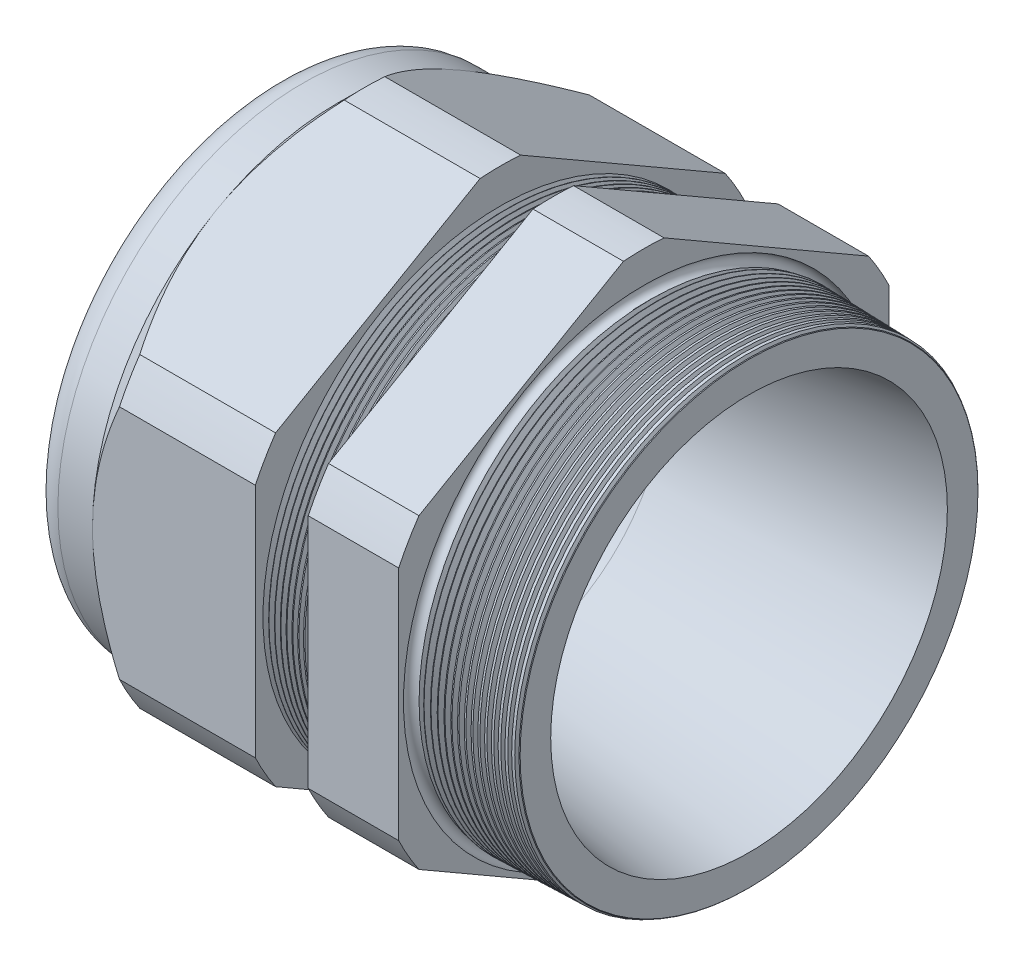
from build123d import *

# Parameters (mm, degrees)
SKETCH12_OUTSIDE_W = 170.928
SKETCH12_OUTSIDE_H = 170.928
CUT_EXTRUDE2_DEPTH = 55.5920168
FILLET4_R          = 3.81
SKETCH19_OUTSIDE_W = 98.176
SKETCH19_OUTSIDE_H = 105.328
SKETCH19_OUTSIDE_R = 32.512
CUT_EXTRUDE3_DEPTH = 3.99796
CUT_EXTRUDE3_DRAFT = -45
CHAMFER1_SIZE      = 0.260919487
CHAMFER1_SIZE2     = 0.254
SKETCH21_R         = 21.971
PLUG_DEPTH         = 12.7
SKETCH22_R         = 21.717
CUT_EXTRUDE4_DEPTH = 0.508
LPATTERN1_COUNT    = 9
LPATTERN1_PITCH    = 0.762
LPATTERN2_COUNT    = 16
LPATTERN2_PITCH    = 0.889
SKETCH32_R         = 0.889


with BuildPart() as part:
    # Sketch10 → Revolve2 (revolve)
    with BuildSketch(Plane.XY, mode=Mode.PRIVATE) as revolve2_sk:
        Polygon((-56.896, 21.971), (-26.89359112, 21.971), (6.096, 26.314137154), (6.096, 30.632137154), (-7.874, 30.997954479), (-7.874, 65.024), (-19.873976, 65.024), (-19.873976, 31.312184909), (-26.89359112, 31.496), (-26.89359112, 65.024), (-48.4960168, 65.024), (-48.4960168, 32.512), (-56.896, 32.512), align=None)
    revolve(revolve2_sk.sketch.rotate(Axis((0, 0, 0), (-1, 0, 0)), 90), axis=Axis((0, 0, 0), (-1, 0, 0)))  # turned: the seam where the file's is

    # Sketch12 outside → Cut-Extrude2 (cut, through all)
    with BuildSketch(Plane.ZY.offset(48.4960168)):
        Rectangle(SKETCH12_OUTSIDE_W, SKETCH12_OUTSIDE_H)
        with BuildLine():
            Line((-2.69124706, 35.987831689), (-29.82075294, 20.324604167))
            ThreePointArc((-29.82075294, 20.324604167), (-31.2534019, 18.04416), (-32.512, 15.663227523))
            Line((-32.512, 15.663227523), (-32.512, -15.663227523))
            ThreePointArc((-32.512, -15.663227523), (-31.2534019, -18.04416), (-29.82075294, -20.324604167))
            Line((-29.82075294, -20.324604167), (-2.69124706, -35.987831689))
            ThreePointArc((-2.69124706, -35.987831689), (0, -36.08832), (2.69124706, -35.987831689))
            Line((2.69124706, -35.987831689), (29.82075294, -20.324604167))
            ThreePointArc((29.82075294, -20.324604167), (31.2534019, -18.04416), (32.512, -15.663227523))
            Line((32.512, -15.663227523), (32.512, 15.663227523))
            ThreePointArc((32.512, 15.663227523), (31.2534019, 18.04416), (29.82075294, 20.324604167))
            Line((29.82075294, 20.324604167), (2.69124706, 35.987831689))
            ThreePointArc((2.69124706, 35.987831689), (0, 36.08832), (-2.69124706, 35.987831689))
        make_face(mode=Mode.SUBTRACT)
    extrude(amount=-CUT_EXTRUDE2_DEPTH, mode=Mode.SUBTRACT)

    # Fillet4
    fillet4_edges = [part.edges().sort_by_distance(p)[0] for p in [
        (-56.896, 0, 32.512),
    ]]
    fillet(fillet4_edges, radius=FILLET4_R)


with BuildPart() as cut_extrude3_tool:
    # Sketch19 outside → Cut-Extrude3 (with draft: the straight prism first)
    with BuildSketch(Plane.ZY.offset(48.4960168)):
        Rectangle(SKETCH19_OUTSIDE_W, SKETCH19_OUTSIDE_H)
        Circle(SKETCH19_OUTSIDE_R, mode=Mode.SUBTRACT)
    extrude(amount=-CUT_EXTRUDE3_DEPTH)
    # Cut-Extrude3: the draft: its side faces are tilted about the plane it starts from
    cut_extrude3_sides = [cut_extrude3_tool.faces().sort_by_distance(p)[0] for p in [
        (-46.4970368, -52.664, 0),
        (-46.4970368, 0, 49.088),
        (-46.4970368, 52.664, 0),
        (-46.4970368, 0, -49.088),
        (-46.4970368, 0, -32.512),
    ]]
    draft(cut_extrude3_sides, Plane.ZY.offset(48.4960168), CUT_EXTRUDE3_DRAFT)


with BuildPart() as part_1:
    add(part.part)

    # Cut-Extrude3: cut by cut_extrude3_tool
    add(cut_extrude3_tool.part, mode=Mode.SUBTRACT)

    # Chamfer1
    chamfer1_edges = [part_1.edges().sort_by_distance(p)[0] for p in [
        (6.096, 0, 30.632137154),
    ]]
    chamfer1_side = [part_1.faces().sort_by_distance(p)[0] for p in [
        (6.096, 0, 27.18054483),
    ]]
    chamfer(chamfer1_edges, length=CHAMFER1_SIZE, length2=CHAMFER1_SIZE2, reference=chamfer1_side[0])

    # Sketch29 → Cut-Revolve1 (revolve, cut)
    with BuildSketch(Plane.XY, mode=Mode.PRIVATE) as cut_revolve1_sk:
        Polygon((-26.89359112, 31.496), (-26.160607539, 31.476806149), (-26.543721692, 30.851620673), align=None)
    cut_revolve1 = revolve(cut_revolve1_sk.sketch.rotate(Axis((0, 0, 0), (-1, 0, 0)), 90), axis=Axis((0, 0, 0), (-1, 0, 0)), mode=Mode.SUBTRACT)  # turned: the seam where the file's is

    # LPattern1: Cut-Revolve1 ×9
    with Locations(*[(i * LPATTERN1_PITCH, 0, 0) for i in range(1, LPATTERN1_COUNT)]):
        add(cut_revolve1, mode=Mode.SUBTRACT)

    # Sketch30 → Cut-Revolve2 (revolve, cut)
    with BuildSketch(Plane.XY, mode=Mode.PRIVATE) as cut_revolve2_sk:
        Polygon((-7.874, 30.997954479), (-6.994419703, 30.974921858), (-7.454156686, 30.224699287), align=None)
    cut_revolve2 = revolve(cut_revolve2_sk.sketch.rotate(Axis((0, 0, 0), (-1, 0, 0)), 270), axis=Axis((0, 0, 0), (-1, 0, 0)), mode=Mode.SUBTRACT)  # turned: the seam where the file's is

    # LPattern2: Cut-Revolve2 ×16
    with Locations(*[(i * LPATTERN2_PITCH, 0, 0) for i in range(1, LPATTERN2_COUNT)]):
        add(cut_revolve2, mode=Mode.SUBTRACT)

    # Sketch32 → Cut-Revolve3 (revolve, cut)
    with BuildSketch(Plane.XY, mode=Mode.PRIVATE) as cut_revolve3_sk:
        with Locations((-7.747, 30.997954479)):
            Circle(SKETCH32_R)
    revolve(cut_revolve3_sk.sketch.rotate(Axis((0, 0, 0), (-1, 0, 0)), 270), axis=Axis((0, 0, 0), (-1, 0, 0)), mode=Mode.SUBTRACT)  # turned: the seam where the file's is


with BuildPart() as body_2:
    # Sketch21 → plug (new body)
    with BuildSketch(Plane.ZY.offset(56.896)):
        Circle(SKETCH21_R)
    extrude(amount=-PLUG_DEPTH)

    # Sketch22 → Cut-Extrude4 (cut)
    with BuildSketch(Plane.ZY.offset(56.896)):
        Circle(SKETCH22_R)
    extrude(amount=-CUT_EXTRUDE4_DEPTH, mode=Mode.SUBTRACT)


solid = Compound([part_1.part, body_2.part])
